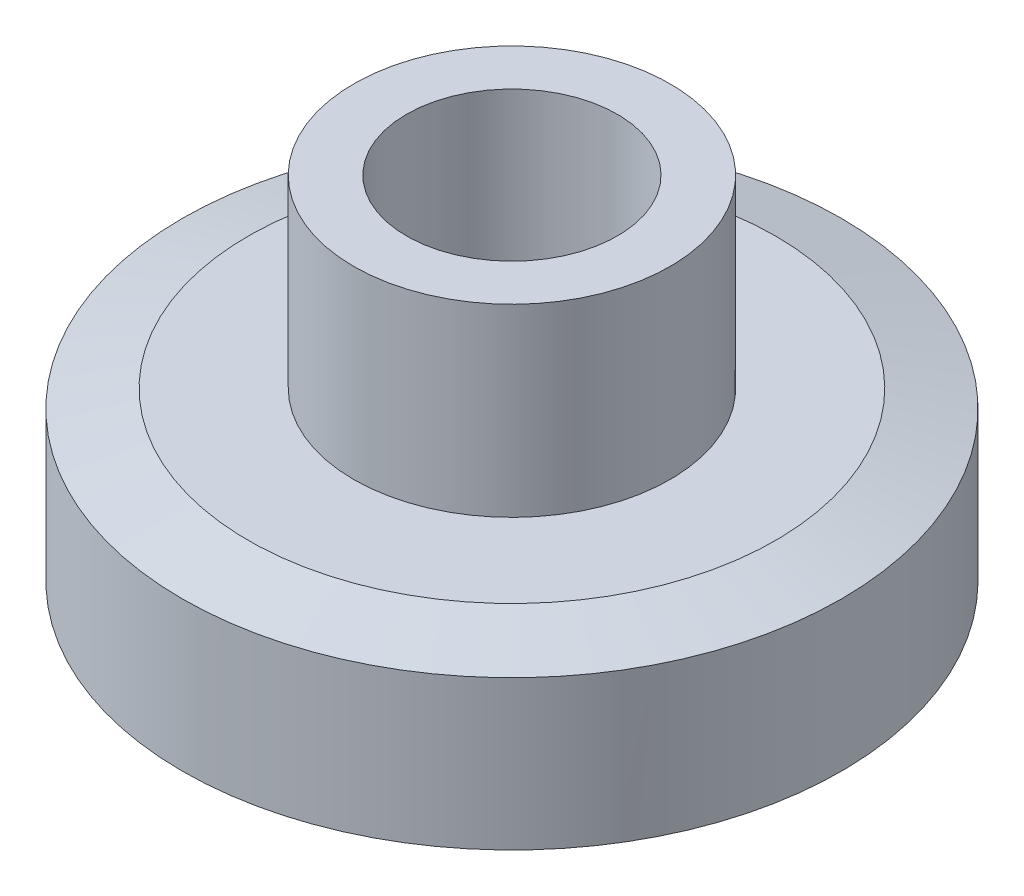
from build123d import *

# Parameters (mm, degrees)
CHAMFER_2_SIZE           = 1.25
CHAMFER_2_SIZE2          = 0.334936491
CHAMFER_3_SIZE           = 1.25
CHAMFER_3_SIZE2          = 0.334936491
SKETCH_4_R               = 2
CUT_EXTRUDE_2_DEPTH      = 1
CUT_EXTRUDE_2_DEPTH_BACK = 8


with BuildPart() as part:
    # Эскиз2 → Повернуть2 (revolve)
    with BuildSketch(Plane.XY):
        Polygon((0, 0), (6.25, 0), (6.25, 3.5), (3, 3.5), (3, 7), (0, 7), align=None)
    revolve(axis=Axis((0, 7, 0), (0, -1, 0)))

    # Фаска2
    chamfer_2_edges = [part.edges().sort_by_distance(p)[0] for p in [
        (-6.25, 3.5, 0),
    ]]
    chamfer_2_side = [part.faces().sort_by_distance(p)[0] for p in [
        (-6.073223305, 3.5, 0),
    ]]
    chamfer(chamfer_2_edges, length=CHAMFER_2_SIZE, length2=CHAMFER_2_SIZE2, reference=chamfer_2_side[0])

    # Фаска3
    chamfer_3_edges = [part.edges().sort_by_distance(p)[0] for p in [
        (-6.25, 0, 0),
    ]]
    chamfer_3_side = [part.faces().sort_by_distance(p)[0] for p in [
        (0, 0, 0),
    ]]
    chamfer(chamfer_3_edges, length=CHAMFER_3_SIZE, length2=CHAMFER_3_SIZE2, reference=chamfer_3_side[0])

    # Эскиз4 → Вырез-Вытянуть2 (cut, two sides)
    with BuildSketch(Plane(origin=(0, 7, 0), x_dir=(1, 0, 0), z_dir=(0, 1, 0))) as cut_extrude_2_sk:
        Circle(SKETCH_4_R)
    extrude(amount=CUT_EXTRUDE_2_DEPTH, mode=Mode.SUBTRACT)
    extrude(cut_extrude_2_sk.sketch, amount=-CUT_EXTRUDE_2_DEPTH_BACK, mode=Mode.SUBTRACT)


solid = part.part
